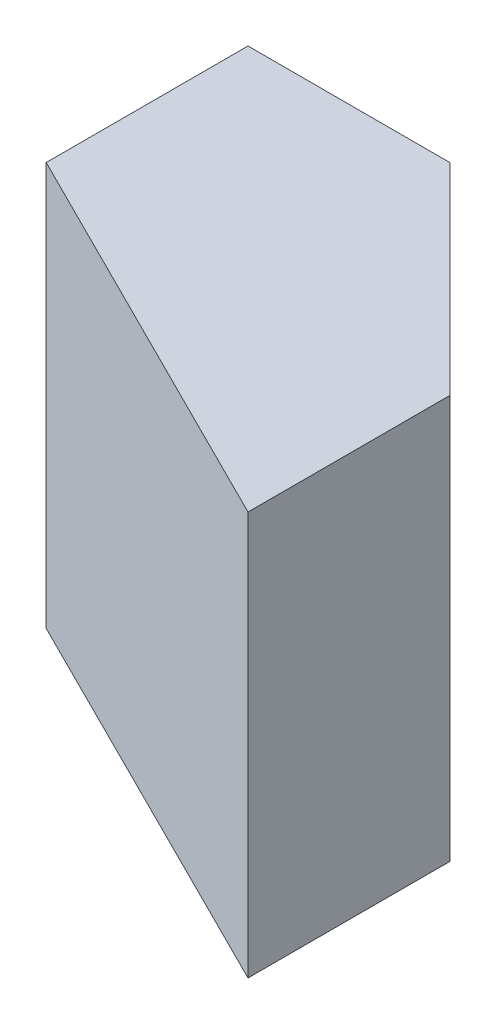
from build123d import *

# Parameters (mm, degrees)
SKETCH1_W           = 20
SKETCH1_H           = 20
BOSS_EXTRUDE1_DEPTH = 20
CUT_EXTRUDE1_DEPTH  = 20
CUT_EXTRUDE2_DEPTH  = 20


with BuildPart() as part:
    # Sketch1 → Boss-Extrude1 (new body)
    with BuildSketch(Plane.XY):
        with Locations((10, 10)):
            Rectangle(SKETCH1_W, SKETCH1_H)
    extrude(amount=BOSS_EXTRUDE1_DEPTH)

    # Sketch2 → Cut-Extrude1 (cut)
    with BuildSketch(Plane(origin=(0, 20, 0), x_dir=(1, 0, 0), z_dir=(0, 1, 0))):
        Polygon((20, 0), (10, 0), (20, -10), align=None)
    extrude(amount=-CUT_EXTRUDE1_DEPTH, mode=Mode.SUBTRACT)

    # Sketch3 → Cut-Extrude2 (cut)
    with BuildSketch(Plane(origin=(0, 20, 0), x_dir=(1, 0, 0), z_dir=(0, 1, 0))):
        Polygon((20, -20), (0, -20), (0, -10), align=None)
    extrude(amount=-CUT_EXTRUDE2_DEPTH, mode=Mode.SUBTRACT)


solid = part.part
